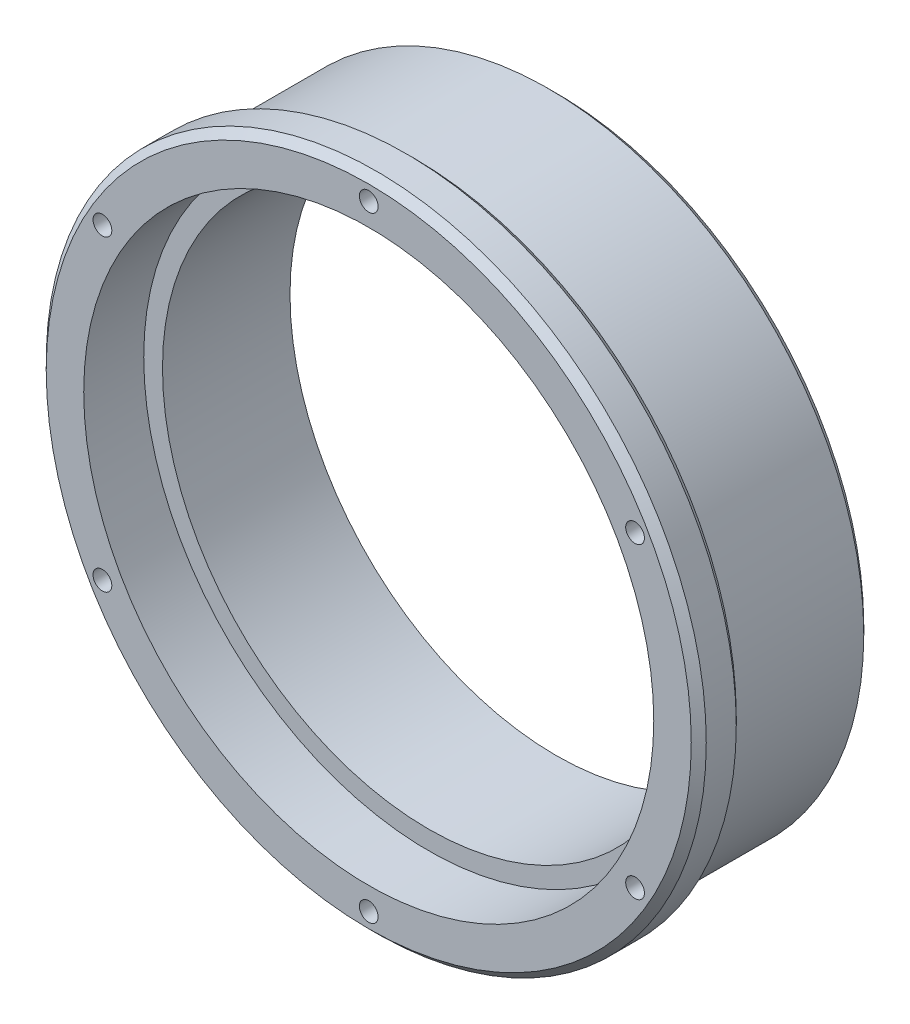
from build123d import *

# Parameters (mm, degrees)
SKETCH_1_R                       = 42
SKETCH_1_R_2                     = 35.5
EXTRUDE_1_DEPTH                  = 25
SKETCH_2_R                       = 38
CUT_EXTRUDE_1_DEPTH              = 8
HOLE_WIZARD_M3_1_D               = 2.5
HOLE_WIZARD_M3_1_DEPTH           = 6
HOLE_WIZARD_M3_1_TIP             = 0.751075774
SKETCH_10_R                      = 44
SKETCH_10_R_2                    = 42
EXTRUDE_2_DEPTH                  = 6
CHAMFER_1_SIZE                   = 1
HOLE_WIZARD_M3_3_D               = 2.5
HOLE_WIZARD_M3_3_DEPTH           = 5
HOLE_WIZARD_M3_3_TIP             = 0.751075774
HOLE_WIZARD_M3_3_ON_FACE_2_D     = 2.5
HOLE_WIZARD_M3_3_ON_FACE_2_DEPTH = 5
HOLE_WIZARD_M3_3_ON_FACE_2_TIP   = 0.751075774
CHAMFER_2_SIZE                   = 1


with BuildPart() as part:
    # 草图1 → 凸台-拉伸1 (new body)
    with BuildSketch(Plane.XY):
        Circle(SKETCH_1_R)
        Circle(SKETCH_1_R_2, mode=Mode.SUBTRACT)
    extrude(amount=EXTRUDE_1_DEPTH)

    # 草图2 → 切除-拉伸1 (cut)
    with BuildSketch(Plane.XY.offset(25)):
        Circle(SKETCH_2_R)
    extrude(amount=-CUT_EXTRUDE_1_DEPTH, mode=Mode.SUBTRACT)

    # M3 螺纹孔1
    with Locations(Plane(origin=(-33.341978046, 19.25, 0), x_dir=(-1, 0, 0), z_dir=(0, 0, -1))):
        with Locations((0, 0), (0, -38.5), (-33.341978046, -57.75), (-66.683956092, -38.5), (-66.683956092, 0), (-33.341978046, 19.25)):
            Hole(HOLE_WIZARD_M3_1_D / 2, depth=HOLE_WIZARD_M3_1_DEPTH)
            with Locations((0, 0, -(HOLE_WIZARD_M3_1_DEPTH + HOLE_WIZARD_M3_1_TIP / 2))):  # 118° drill point
                Cone(0, HOLE_WIZARD_M3_1_D / 2, HOLE_WIZARD_M3_1_TIP, mode=Mode.SUBTRACT)

    # 草图10 → 凸台-拉伸2 (add)
    with BuildSketch(Plane.XY.offset(25)):
        Circle(SKETCH_10_R)
        Circle(SKETCH_10_R_2, mode=Mode.SUBTRACT)
    extrude(amount=-EXTRUDE_2_DEPTH)

    # 倒角1
    chamfer_1_edges = [part.edges().sort_by_distance(p)[0] for p in [
        (-42, 0, 0),
    ]]
    chamfer(chamfer_1_edges, length=CHAMFER_1_SIZE)

    # M3 螺纹孔3
    with Locations(Plane(origin=(35.507041555, 20.5, 25), x_dir=(1, 0, 0), z_dir=(0, 0, 1))):
        with Locations((0, 0), (0, -41), (-35.507041555, 20.5), (-35.507041555, -61.5), (-71.01408311, -41), (-71.01408311, 0)):
            Hole(HOLE_WIZARD_M3_3_D / 2, depth=HOLE_WIZARD_M3_3_DEPTH)
            with Locations((0, 0, -(HOLE_WIZARD_M3_3_DEPTH + HOLE_WIZARD_M3_3_TIP / 2))):  # 118° drill point
                Cone(0, HOLE_WIZARD_M3_3_D / 2, HOLE_WIZARD_M3_3_TIP, mode=Mode.SUBTRACT)

    # M3 螺纹孔3 on face 2
    with Locations(Plane(origin=(84.616598131, -20.470458883, 0), x_dir=(1, 0, 0), z_dir=(0, 0, 1))):
        with Locations((0, 0)):
            Hole(HOLE_WIZARD_M3_3_ON_FACE_2_D / 2, depth=HOLE_WIZARD_M3_3_ON_FACE_2_DEPTH)
            with Locations((0, 0, -(HOLE_WIZARD_M3_3_ON_FACE_2_DEPTH + HOLE_WIZARD_M3_3_ON_FACE_2_TIP / 2))):  # 118° drill point
                Cone(0, HOLE_WIZARD_M3_3_ON_FACE_2_D / 2, HOLE_WIZARD_M3_3_ON_FACE_2_TIP, mode=Mode.SUBTRACT)

    # 倒角2
    chamfer_2_edges = [part.edges().sort_by_distance(p)[0] for p in [
        (-44, 0, 19),
        (-44, 0, 25),
    ]]
    chamfer(chamfer_2_edges, length=CHAMFER_2_SIZE)


solid = part.part
